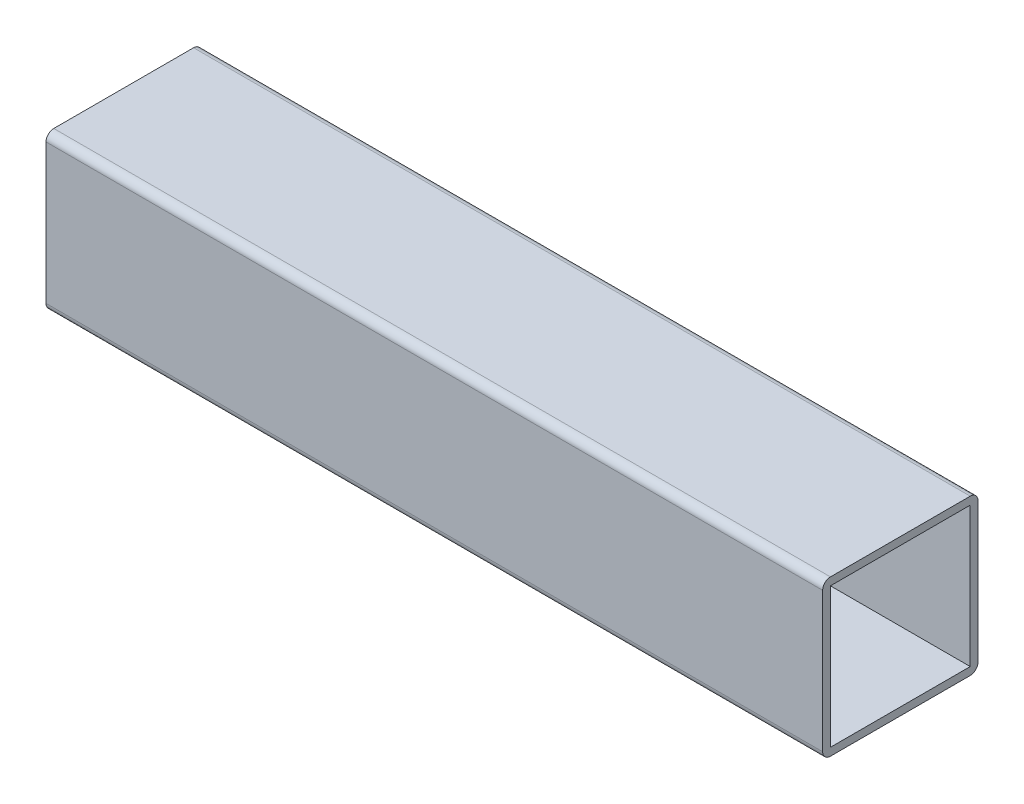
from build123d import *

# Parameters (mm, degrees)
SKETCH_1_W      = 54
SKETCH_1_H      = 54
EXTRUDE_2_DEPTH = 300


with BuildPart() as part:
    # Эскиз1 → Вытянуть-Тонкостенный2 (new body)
    with BuildSketch(Plane(origin=(0, 0, 0), x_dir=(0, 0, -1), z_dir=(1, 0, 0))):
        with BuildLine():
            Line((-27, 30), (27, 30))
            ThreePointArc((27, 30), (29.121320344, 29.121320344), (30, 27))
            Line((30, 27), (30, -27))
            ThreePointArc((30, -27), (29.121320344, -29.121320344), (27, -30))
            Line((27, -30), (-27, -30))
            ThreePointArc((-27, -30), (-29.121320344, -29.121320344), (-30, -27))
            Line((-30, -27), (-30, 27))
            ThreePointArc((-30, 27), (-29.121320344, 29.121320344), (-27, 30))
        make_face()
        Rectangle(SKETCH_1_W, SKETCH_1_H, mode=Mode.SUBTRACT)
    extrude(amount=EXTRUDE_2_DEPTH)


solid = part.part
